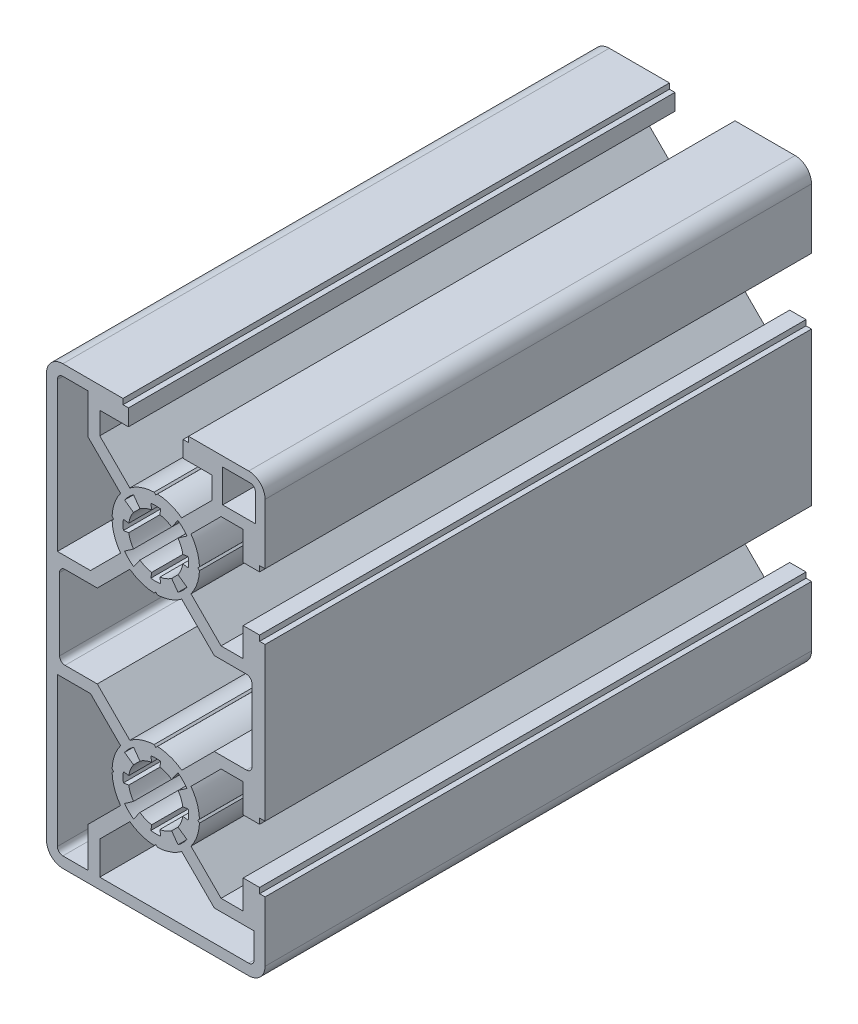
from build123d import *

# Parameters (mm, degrees)
Y_KSEKLIK_EKSTR_ZYON1_DEPTH = 100


with BuildPart() as part:
    # Çizim1 → Yükseklik-Ekstrüzyon1 (new body)
    with BuildSketch(Plane.XY.offset(100)):
        with BuildLine():
            Line((20, 26.000000009), (20, 37))
            ThreePointArc((20, 37), (19.121320344, 39.121320344), (17, 40))
            Line((17, 40), (6, 40))
            Line((6, 40), (6, 39))
            Line((6, 39), (5, 39))
            Line((5, 39), (5, 36))
            Line((5, 36), (10.249999999, 36))
            Line((10.249999999, 36), (10.249999999, 31.947056282))
            Line((10.249999999, 31.947056282), (4.744324442, 26.441380723))
            ThreePointArc((4.744324442, 26.441380723), (2.642011932, 27.55114382), (0.306405969, 27.994130061))
            Line((0.306405969, 27.994130061), (0, 27.700000003))
            Line((0, 27.700000003), (-0.306405971, 27.994130061))
            ThreePointArc((-0.306405971, 27.994130061), (-2.642011934, 27.55114382), (-4.744324444, 26.441380722))
            Line((-4.744324444, 26.441380722), (-10.25, 31.947056275))
            Line((-10.25, 31.947056275), (-10.25, 36))
            Line((-10.25, 36), (-5, 36))
            Line((-5, 36), (-5, 39))
            Line((-5, 39), (-6, 39))
            Line((-6, 39), (-6, 40))
            Line((-6, 40), (-17, 40))
            ThreePointArc((-17, 40), (-19.121320344, 39.121320344), (-20, 37))
            Line((-20, 37), (-20, -37))
            ThreePointArc((-20, -37), (-19.121320344, -39.121320344), (-17, -40))
            Line((-17, -40), (17, -40))
            ThreePointArc((17, -40), (19.121320344, -39.121320344), (20, -37))
            Line((20, -37), (20, -25.999999991))
            Line((20, -25.999999991), (19.000000009, -25.999999991))
            Line((19.000000009, -25.999999991), (19.000000009, -24.999999991))
            Line((19.000000009, -24.999999991), (16.000000009, -24.999999991))
            Line((16.000000009, -24.999999991), (16.000000009, -30.249999991))
            Line((16.000000009, -30.249999991), (11.947056284, -30.249999991))
            Line((11.947056284, -30.249999991), (6.441380724, -24.744324437))
            ThreePointArc((6.441380724, -24.744324437), (7.551143818, -22.642011929), (7.994130058, -20.30640597))
            Line((7.994130058, -20.30640597), (7.7, -20))
            Line((7.7, -20), (7.994130058, -19.693594031))
            ThreePointArc((7.994130058, -19.693594031), (7.551143817, -17.357988066), (6.441380719, -15.255675555))
            Line((6.441380719, -15.255675555), (11.947056274, -9.75))
            Line((11.947056274, -9.75), (16.000000009, -9.75))
            Line((16.000000009, -9.75), (16.000000009, -14.999999991))
            Line((16.000000009, -14.999999991), (19.000000009, -14.999999991))
            Line((19.000000009, -14.999999991), (19.000000009, -13.999999991))
            Line((19.000000009, -13.999999991), (20, -13.999999991))
            Line((20, -13.999999991), (20, 14.000000009))
            Line((20, 14.000000009), (19.000000009, 14.000000009))
            Line((19.000000009, 14.000000009), (19.000000009, 15.000000009))
            Line((19.000000009, 15.000000009), (16.000000009, 15.000000009))
            Line((16.000000009, 15.000000009), (16.000000009, 9.750000006))
            Line((16.000000009, 9.750000006), (11.947056278, 9.750000006))
            Line((11.947056278, 9.750000006), (6.441380721, 15.255675562))
            ThreePointArc((6.441380721, 15.255675562), (7.551143817, 17.357988072), (7.994130058, 19.693594034))
            Line((7.994130058, 19.693594034), (7.699999999, 20.000000003))
            Line((7.699999999, 20.000000003), (7.994130057, 20.306405974))
            ThreePointArc((7.994130057, 20.306405974), (7.551143818, 22.642011933), (6.441380724, 24.74432444))
            Line((6.441380724, 24.74432444), (11.947056283, 30.249999994))
            Line((11.947056283, 30.249999994), (16.000000009, 30.249999994))
            Line((16.000000009, 30.249999994), (16.000000009, 25.000000009))
            Line((16.000000009, 25.000000009), (19.000000009, 25.000000009))
            Line((19.000000009, 25.000000009), (19.000000009, 26.000000009))
            Line((19.000000009, 26.000000009), (20, 26.000000009))
        make_face()
        with BuildLine():
            Line((-5.705709704, 15.944771677), (-4.075506937, 17.103408337))
            ThreePointArc((-4.075506937, 17.103408337), (-4.635549589, 18.126052276), (-4.943520623, 19.250597625))
            Line((-4.943520623, 19.250597625), (-5.932224739, 19.10071715))
            ThreePointArc((-5.932224739, 19.10071715), (-6, 20.000000003), (-5.932224739, 20.899282856))
            Line((-5.932224739, 20.899282856), (-4.943520623, 20.749402382))
            ThreePointArc((-4.943520623, 20.749402382), (-4.635549589, 21.87394773), (-4.075506938, 22.896591669))
            Line((-4.075506938, 22.896591669), (-5.705709704, 24.055228329))
            ThreePointArc((-5.705709704, 24.055228329), (-4.953610357, 24.945881566), (-4.064132573, 25.699370708))
            Line((-4.064132573, 25.699370708), (-2.902951842, 24.070979084))
            ThreePointArc((-2.902951842, 24.070979084), (-1.87756625, 24.634085139), (-0.749402378, 24.943520626))
            Line((-0.749402378, 24.943520626), (-0.899282852, 25.932224742))
            ThreePointArc((-0.899282852, 25.932224742), (-1e-09, 26.000000003), (0.899282851, 25.932224742))
            Line((0.899282851, 25.932224742), (0.749402377, 24.943520626))
            ThreePointArc((0.749402377, 24.943520626), (1.87756625, 24.634085139), (2.902951843, 24.070979083))
            Line((2.902951843, 24.070979083), (4.064132574, 25.699370707))
            ThreePointArc((4.064132574, 25.699370707), (4.953610357, 24.945881565), (5.705709703, 24.055228329))
            Line((5.705709703, 24.055228329), (4.075506937, 22.896591669))
            ThreePointArc((4.075506937, 22.896591669), (4.635549589, 21.87394773), (4.943520622, 20.749402381))
            Line((4.943520622, 20.749402381), (5.932224738, 20.899282855))
            ThreePointArc((5.932224738, 20.899282855), (6, 20.000000003), (5.932224738, 19.10071715))
            Line((5.932224738, 19.10071715), (4.943520622, 19.250597624))
            ThreePointArc((4.943520622, 19.250597624), (4.635549588, 18.126052276), (4.075506937, 17.103408337))
            Line((4.075506937, 17.103408337), (5.705709704, 15.944771677))
            ThreePointArc((5.705709704, 15.944771677), (4.953610357, 15.05411844), (4.064132573, 14.300629298))
            Line((4.064132573, 14.300629298), (2.902951842, 15.929020922))
            ThreePointArc((2.902951842, 15.929020922), (1.877566249, 15.365914867), (0.749402377, 15.05647938))
            Line((0.749402377, 15.05647938), (0.899282852, 14.067775264))
            ThreePointArc((0.899282852, 14.067775264), (0, 14.000000003), (-0.899282852, 14.067775264))
            Line((-0.899282852, 14.067775264), (-0.749402377, 15.05647938))
            ThreePointArc((-0.749402377, 15.05647938), (-1.87756625, 15.365914867), (-2.902951843, 15.929020923))
            Line((-2.902951843, 15.929020923), (-4.064132575, 14.300629299))
            ThreePointArc((-4.064132575, 14.300629299), (-4.953610358, 15.054118441), (-5.705709704, 15.944771677))
        make_face(mode=Mode.SUBTRACT)
        with BuildLine():
            Line((-5.705709703, -24.055228326), (-4.075506937, -22.896591665))
            ThreePointArc((-4.075506937, -22.896591665), (-4.635549589, -21.873947726), (-4.943520623, -20.749402378))
            Line((-4.943520623, -20.749402378), (-5.932224739, -20.899282852))
            ThreePointArc((-5.932224739, -20.899282852), (-6, -19.999999999), (-5.932224738, -19.100717147))
            Line((-5.932224738, -19.100717147), (-4.943520623, -19.250597621))
            ThreePointArc((-4.943520623, -19.250597621), (-4.635549589, -18.126052273), (-4.075506937, -17.103408334))
            Line((-4.075506937, -17.103408334), (-5.705709704, -15.944771674))
            ThreePointArc((-5.705709704, -15.944771674), (-4.953610357, -15.054118437), (-4.064132573, -14.300629295))
            Line((-4.064132573, -14.300629295), (-2.902951842, -15.929020919))
            ThreePointArc((-2.902951842, -15.929020919), (-1.87756625, -15.365914863), (-0.749402377, -15.056479377))
            Line((-0.749402377, -15.056479377), (-0.899282852, -14.067775261))
            ThreePointArc((-0.899282852, -14.067775261), (0, -14), (0.899282851, -14.067775261))
            Line((0.899282851, -14.067775261), (0.749402377, -15.056479377))
            ThreePointArc((0.749402377, -15.056479377), (1.87756625, -15.365914864), (2.902951843, -15.92902092))
            Line((2.902951843, -15.92902092), (4.064132575, -14.300629296))
            ThreePointArc((4.064132575, -14.300629296), (4.953610358, -15.054118438), (5.705709704, -15.944771673))
            Line((5.705709704, -15.944771673), (4.075506937, -17.103408334))
            ThreePointArc((4.075506937, -17.103408334), (4.635549589, -18.126052273), (4.943520623, -19.250597622))
            Line((4.943520623, -19.250597622), (5.932224739, -19.100717147))
            ThreePointArc((5.932224739, -19.100717147), (6, -20), (5.932224739, -20.899282853))
            Line((5.932224739, -20.899282853), (4.943520623, -20.749402378))
            ThreePointArc((4.943520623, -20.749402378), (4.635549589, -21.873947726), (4.075506937, -22.896591665))
            Line((4.075506937, -22.896591665), (5.705709704, -24.055228326))
            ThreePointArc((5.705709704, -24.055228326), (4.953610357, -24.945881562), (4.064132573, -25.699370704))
            Line((4.064132573, -25.699370704), (2.902951842, -24.07097908))
            ThreePointArc((2.902951842, -24.07097908), (1.87756625, -24.634085136), (0.749402378, -24.943520623))
            Line((0.749402378, -24.943520623), (0.899282852, -25.932224739))
            ThreePointArc((0.899282852, -25.932224739), (1e-09, -26), (-0.899282851, -25.932224739))
            Line((-0.899282851, -25.932224739), (-0.749402377, -24.943520623))
            ThreePointArc((-0.749402377, -24.943520623), (-1.87756625, -24.634085136), (-2.902951843, -24.07097908))
            Line((-2.902951843, -24.07097908), (-4.064132574, -25.699370703))
            ThreePointArc((-4.064132574, -25.699370703), (-4.953610357, -24.945881562), (-5.705709703, -24.055228326))
        make_face(mode=Mode.SUBTRACT)
        with BuildLine():
            Line((18.25, 32.25), (12.25, 32.25))
            Line((12.25, 32.25), (12.25, 38.25))
            Line((12.25, 38.25), (17.25, 38.25))
            ThreePointArc((17.25, 38.25), (17.957106781, 37.957106781), (18.25, 37.25))
            Line((18.25, 37.25), (18.25, 32.25))
        make_face(mode=Mode.SUBTRACT)
        with BuildLine():
            Line((-11.94705627, 9.750000006), (-18, 9.750000006))
            Line((-18, 9.750000006), (-18, 37))
            ThreePointArc((-18, 37), (-17.707106781, 37.707106781), (-17, 38))
            Line((-17, 38), (-12.400000001, 38))
            Line((-12.400000001, 38), (-12.400000001, 30.702943728))
            Line((-12.400000001, 30.702943728), (-6.44138072, 24.744324447))
            ThreePointArc((-6.44138072, 24.744324447), (-7.551143817, 22.642011936), (-7.994130058, 20.306405972))
            Line((-7.994130058, 20.306405972), (-7.7, 20.000000003))
            Line((-7.7, 20.000000003), (-7.994130058, 19.693594032))
            ThreePointArc((-7.994130058, 19.693594032), (-7.551143817, 17.357988069), (-6.441380719, 15.255675559))
            Line((-6.441380719, 15.255675559), (-11.94705627, 9.750000006))
        make_face(mode=Mode.SUBTRACT)
        with BuildLine():
            Line((-18, -9.75), (-11.947056275, -9.75))
            Line((-11.947056275, -9.75), (-6.441380719, -15.255675556))
            ThreePointArc((-6.441380719, -15.255675556), (-7.551143817, -17.357988066), (-7.994130058, -19.693594029))
            Line((-7.994130058, -19.693594029), (-7.7, -20))
            Line((-7.7, -20), (-7.994130058, -20.306405969))
            ThreePointArc((-7.994130058, -20.306405969), (-7.551143817, -22.642011932), (-6.441380719, -24.744324443))
            Line((-6.441380719, -24.744324443), (-12.400000001, -30.702943724))
            Line((-12.400000001, -30.702943724), (-12.400000001, -38))
            Line((-12.400000001, -38), (-17, -38))
            ThreePointArc((-17, -38), (-17.707106781, -37.707106781), (-18, -37))
            Line((-18, -37), (-18, -9.75))
        make_face(mode=Mode.SUBTRACT)
        with BuildLine():
            Line((-10.25, -38), (-10.25, -31.947056275))
            Line((-10.25, -31.947056275), (-4.744324444, -26.441380719))
            ThreePointArc((-4.744324444, -26.441380719), (-2.642011934, -27.551143816), (-0.306405971, -27.994130057))
            Line((-0.306405971, -27.994130057), (0, -27.699999999))
            Line((0, -27.699999999), (0.306405969, -27.994130058))
            ThreePointArc((0.306405969, -27.994130058), (2.642011933, -27.551143817), (4.744324444, -26.441380719))
            Line((4.744324444, -26.441380719), (10.702943726, -32.400000001))
            Line((10.702943726, -32.400000001), (18, -32.400000001))
            Line((18, -32.400000001), (18, -37))
            ThreePointArc((18, -37), (17.707106781, -37.707106781), (17, -38))
            Line((17, -38), (-10.25, -38))
        make_face(mode=Mode.SUBTRACT)
        with BuildLine():
            Line((-16.6, 7.600000003), (-10.702943728, 7.600000003))
            Line((-10.702943728, 7.600000003), (-4.744324443, 13.558619283))
            ThreePointArc((-4.744324443, 13.558619283), (-2.642011933, 12.448856186), (-0.306405969, 12.005869945))
            Line((-0.306405969, 12.005869945), (0, 12.300000003))
            Line((0, 12.300000003), (0.30640597, 12.005869945))
            ThreePointArc((0.30640597, 12.005869945), (2.642011933, 12.448856186), (4.744324443, 13.558619284))
            Line((4.744324443, 13.558619284), (10.702943724, 7.600000003))
            Line((10.702943724, 7.600000003), (16.6, 7.600000003))
            ThreePointArc((16.6, 7.600000003), (17.307106782, 7.307106784), (17.6, 6.600000003))
            Line((17.6, 6.600000003), (17.6, -6.6))
            ThreePointArc((17.6, -6.6), (17.307106782, -7.307106781), (16.6, -7.6))
            Line((16.6, -7.6), (10.702943725, -7.6))
            Line((10.702943725, -7.6), (4.744324444, -13.55861928))
            ThreePointArc((4.744324444, -13.55861928), (2.642011934, -12.448856183), (0.306405971, -12.005869942))
            Line((0.306405971, -12.005869942), (0, -12.3))
            Line((0, -12.3), (-0.306405969, -12.005869942))
            ThreePointArc((-0.306405969, -12.005869942), (-2.642011932, -12.448856182), (-4.744324443, -13.55861928))
            Line((-4.744324443, -13.55861928), (-10.702943727, -7.6))
            Line((-10.702943727, -7.6), (-16.6, -7.6))
            ThreePointArc((-16.6, -7.6), (-17.307106781, -7.307106781), (-17.6, -6.6))
            Line((-17.6, -6.6), (-17.6, 6.600000003))
            ThreePointArc((-17.6, 6.600000003), (-17.307106781, 7.307106784), (-16.6, 7.600000003))
        make_face(mode=Mode.SUBTRACT)
    extrude(amount=-Y_KSEKLIK_EKSTR_ZYON1_DEPTH)


solid = part.part
